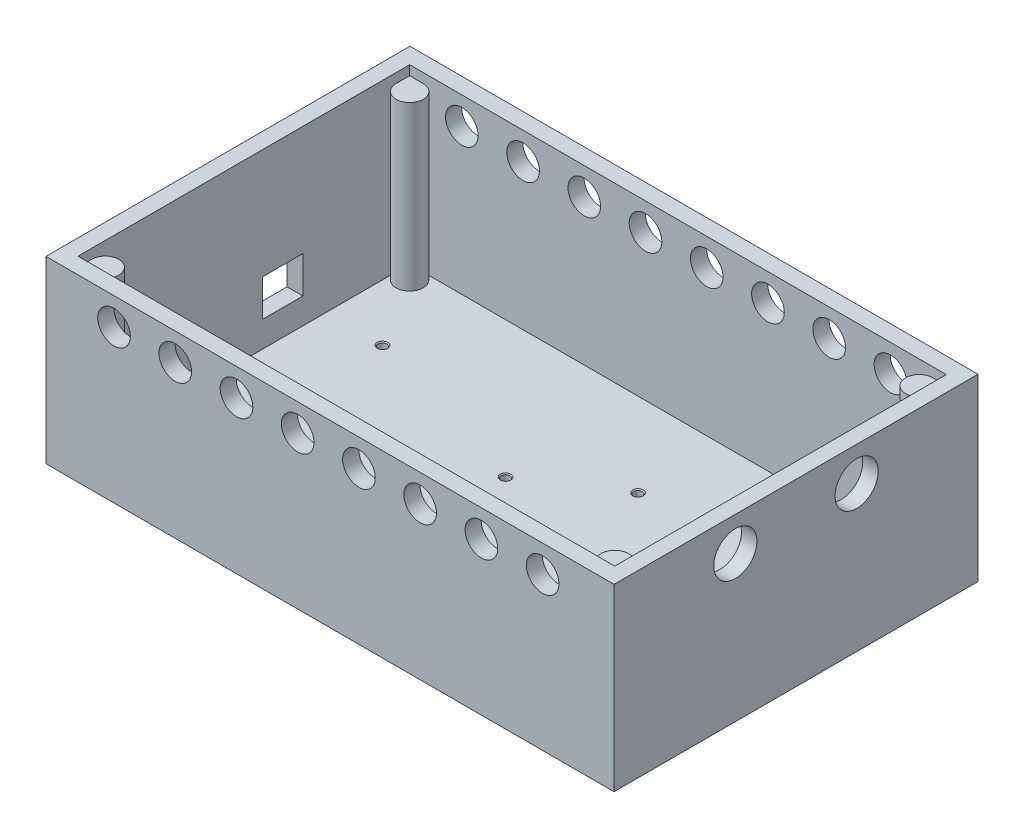
from build123d import *

# Parameters (mm, degrees)
SKETCH1_W                   = 167
SKETCH1_H                   = 107
BOSS_EXTRUDE1_DEPTH         = 52.8
SKETCH2_W                   = 157.8
SKETCH2_H                   = 97.5
CUT_EXTRUDE1_DEPTH          = 50.8
SKETCH3_R                   = 4.8
CUT_EXTRUDE2_DEPTH          = 108
LPATTERN1_COUNT             = 8
LPATTERN1_PITCH             = 18
SKETCH4_R                   = 6.35
CUT_EXTRUDE3_DEPTH          = 4.55
LPATTERN2_COUNT             = 2
LPATTERN2_PITCH             = 35.66
CUT_EXTRUDE4_REACH          = 169
SKETCH5_W                   = 11.94
SKETCH5_H                   = 10.8
BOSS_EXTRUDE5_DEPTH         = 48
M3_TAPPED_HOLE1_D           = 2.5
M3_TAPPED_HOLE1_CSINK_D     = 3.05
M3_TAPPED_HOLE1_CSINK_ANGLE = 90


with BuildPart() as part:
    # Sketch1 → Boss-Extrude1 (new body)
    with BuildSketch(Plane(origin=(0, 0, 0), x_dir=(1, 0, 0), z_dir=(0, 1, 0))):
        with Locations((-12.690388251, -10.711139896)):
            Rectangle(SKETCH1_W, SKETCH1_H)
    extrude(amount=BOSS_EXTRUDE1_DEPTH)

    # Sketch2 → Cut-Extrude1 (cut)
    with BuildSketch(Plane(origin=(0, 52.8, 0), x_dir=(1, 0, 0), z_dir=(0, 1, 0))):
        with Locations((-12.640388251, -10.711139896)):
            Rectangle(SKETCH2_W, SKETCH2_H)
    extrude(amount=-CUT_EXTRUDE1_DEPTH, mode=Mode.SUBTRACT)

    # Sketch3 → Cut-Extrude2 (cut, through all)
    with BuildSketch(Plane.XY.offset(64.211139896)):
        with Locations((-76.190388251, 44.8)):
            Circle(SKETCH3_R)
    cut_extrude2 = extrude(amount=-CUT_EXTRUDE2_DEPTH, mode=Mode.SUBTRACT)

    # LPattern1: Cut-Extrude2 ×8
    with Locations(*[(i * LPATTERN1_PITCH, 0, 0) for i in range(1, LPATTERN1_COUNT)]):
        add(cut_extrude2, mode=Mode.SUBTRACT)

    # Sketch4 → Cut-Extrude3 (cut)
    with BuildSketch(Plane(origin=(70.809611749, 0, 0), x_dir=(0, 0, -1), z_dir=(1, 0, 0))):
        with Locations((-28.551139896, 42.8)):
            Circle(SKETCH4_R)
    cut_extrude3 = extrude(amount=-CUT_EXTRUDE3_DEPTH, mode=Mode.SUBTRACT)

    # LPattern2: Cut-Extrude3 ×2
    with Locations(*[(0, 0, -i * LPATTERN2_PITCH) for i in range(1, LPATTERN2_COUNT)]):
        add(cut_extrude3, mode=Mode.SUBTRACT)

    # Sketch5 → Cut-Extrude4 (cut, up to next)
    with BuildSketch(Plane.ZY.offset(96.190388251), mode=Mode.PRIVATE) as cut_extrude4_sk1:
        with Locations((-0.698860104, 15)):
            Rectangle(SKETCH5_W, SKETCH5_H)
    cut_extrude4_tool1 = extrude(cut_extrude4_sk1.sketch, amount=-CUT_EXTRUDE4_REACH, mode=Mode.PRIVATE) & part.part
    add(cut_extrude4_tool1.solids().sort_by_distance((-96.190388, 15, -0.69886))[0], mode=Mode.SUBTRACT)

    # Sketch6 → Boss-Extrude5 (add)
    with BuildSketch(Plane(origin=(0, 2, 0), x_dir=(1, 0, 0), z_dir=(0, 1, 0))):
        with BuildLine():
            Line((66.259611749, 34.038860104), (66.259611749, 38.038860104))
            Line((66.259611749, 38.038860104), (62.259611749, 38.038860104))
            ThreePointArc((62.259611749, 38.038860104), (59.431184624, 31.210432979), (66.259611749, 34.038860104))
        make_face()
        with BuildLine():
            Line((66.259611749, -59.461139896), (62.259611749, -59.461139896))
            ThreePointArc((62.259611749, -59.461139896), (59.431184624, -52.632712772), (66.259611749, -55.461139896))
            Line((66.259611749, -55.461139896), (66.259611749, -59.461139896))
        make_face()
        with BuildLine():
            Line((-91.540388251, 38.038860104), (-87.540388251, 38.038860104))
            ThreePointArc((-87.540388251, 38.038860104), (-84.711961126, 31.210432979), (-91.540388251, 34.038860104))
            Line((-91.540388251, 34.038860104), (-91.540388251, 38.038860104))
        make_face()
        with BuildLine():
            Line((-91.540388251, -55.461139896), (-91.540388251, -59.461139896))
            Line((-91.540388251, -59.461139896), (-87.540388251, -59.461139896))
            ThreePointArc((-87.540388251, -59.461139896), (-84.711961126, -52.632712772), (-91.540388251, -55.461139896))
        make_face()
    extrude(amount=BOSS_EXTRUDE5_DEPTH)

    # M3 Tapped Hole1 (through all)
    with Locations(Plane(origin=(-49.02040068, 2, -140.944816831), x_dir=(1, 0, 0), z_dir=(0, 1, 0))):
        with Locations((56.769595429, -175.881156727), (25.768895429, -171.002663961), (-25.856604571, -175.881156727), (-25.856604571, -127.544956727), (49.276595429, -127.544956727), (25.768895429, -142.986463961)):
            CounterSinkHole(M3_TAPPED_HOLE1_D / 2, M3_TAPPED_HOLE1_CSINK_D / 2, counter_sink_angle=M3_TAPPED_HOLE1_CSINK_ANGLE)


solid = part.part
